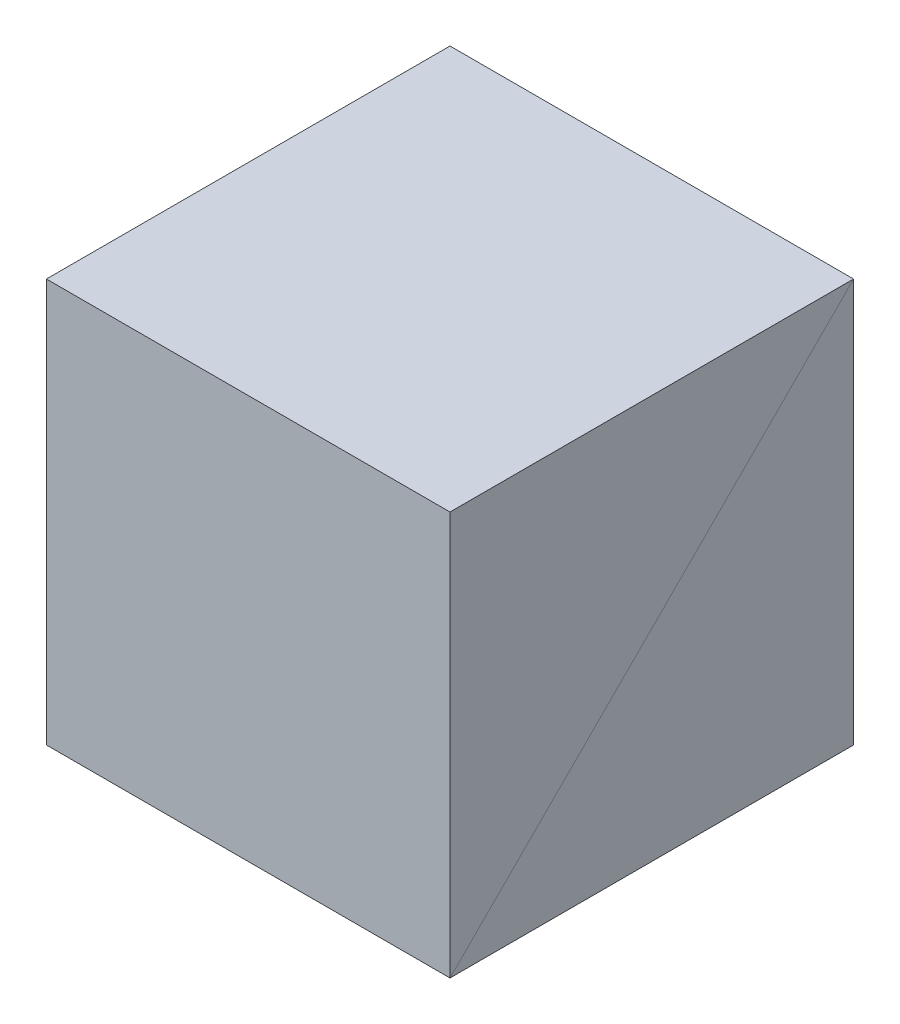
from build123d import *

# Parameters (mm, degrees)
SKETCH1_W           = 200
SKETCH1_H           = 200
BOSS_EXTRUDE1_DEPTH = 200
SKETCH2_W           = 200
SKETCH2_H           = 200
BOSS_EXTRUDE2_DEPTH = 200


with BuildPart() as part:
    # Sketch1 → Boss-Extrude1 (new body)
    with BuildSketch(Plane(origin=(0, 0, 0), x_dir=(1, 0, 0), z_dir=(0, 1, 0))):
        Rectangle(SKETCH1_W, SKETCH1_H)
    extrude(amount=BOSS_EXTRUDE1_DEPTH)


with BuildPart() as body_2:
    # Sketch2 → Boss-Extrude2 (new body)
    with BuildSketch(Plane(origin=(0, 200, 0), x_dir=(1, 0, 0), z_dir=(0, 1, 0))):
        Rectangle(SKETCH2_W, SKETCH2_H)
    extrude(amount=-BOSS_EXTRUDE2_DEPTH)


solid = Compound([part.part, body_2.part])
